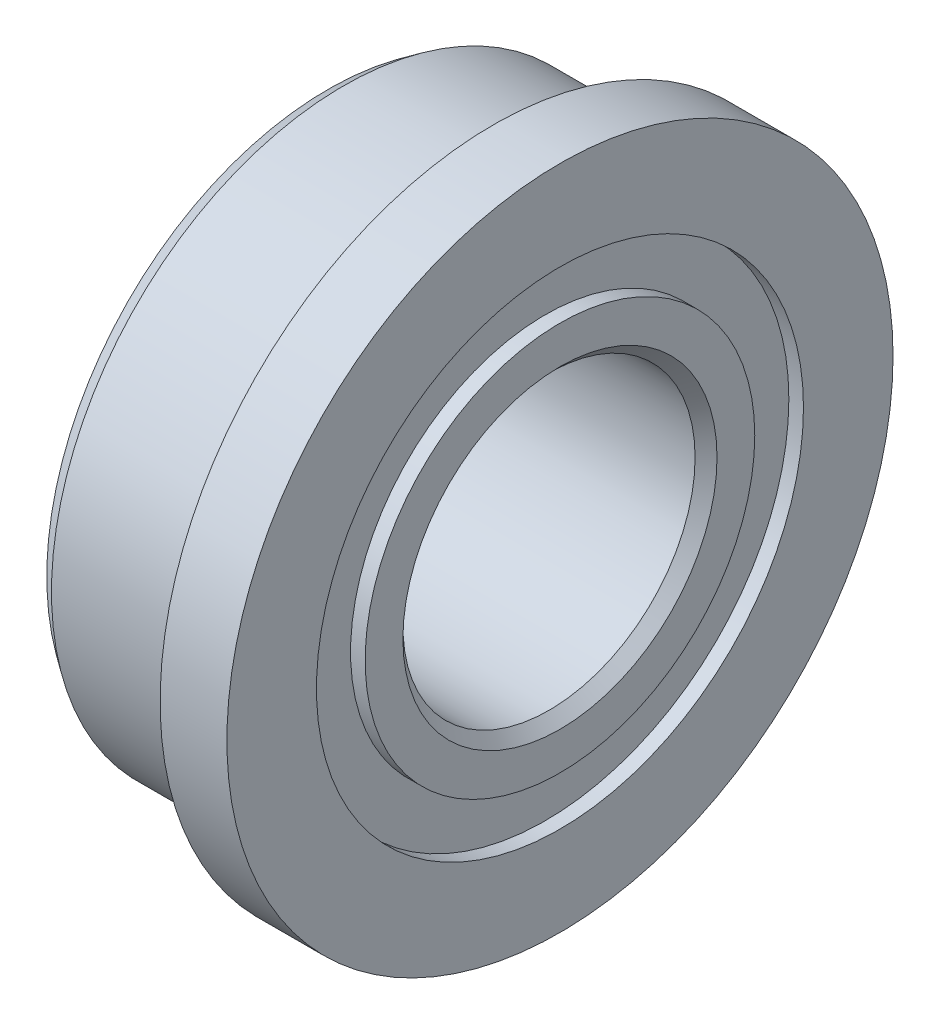
from build123d import *


with BuildPart() as part:
    # Schizzo1 → Rivoluzione1 (revolve)
    with BuildSketch(Plane.XY):
        with BuildLine():
            Line((-2.911073127, 3.333333333), (-2.911073127, 2.666666667))
            Line((-2.911073127, 2.666666667), (-3.175073127, 2.666666667))
            Line((-3.175073127, 2.666666667), (-3.175073127, 2.150104382))
            Line((-3.175073127, 2.150104382), (-2.961146331, 2))
            Line((-2.961146331, 2), (-0.149968672, 2))
            Line((-0.149968672, 2), (-7.3127e-05, 2.150104382))
            Line((-7.3127e-05, 2.150104382), (-7.3127e-05, 2.666666667))
            Line((-7.3127e-05, 2.666666667), (-0.2, 2.666666667))
            Line((-0.2, 2.666666667), (-0.2, 3.333333333))
            Line((-0.2, 3.333333333), (-7.3127e-05, 3.333333333))
            Line((-7.3127e-05, 3.333333333), (-7.3127e-05, 4.5595))
            Line((-7.3127e-05, 4.5595), (-0.914073127, 4.5595))
            Line((-0.914073127, 4.5595), (-0.914073127, 4.02))
            ThreePointArc((-0.914073127, 4.02), (-0.899930992, 3.985857864), (-0.934073127, 4))
            Line((-0.934073127, 4), (-2.961, 4))
            Line((-2.961, 4), (-3.175073127, 3.850104382))
            Line((-3.175073127, 3.850104382), (-3.175073127, 3.333333333))
            Line((-3.175073127, 3.333333333), (-2.911073127, 3.333333333))
        make_face()
    revolve(axis=Axis((-4, 0, 0), (1, 0, 0)))


solid = part.part
